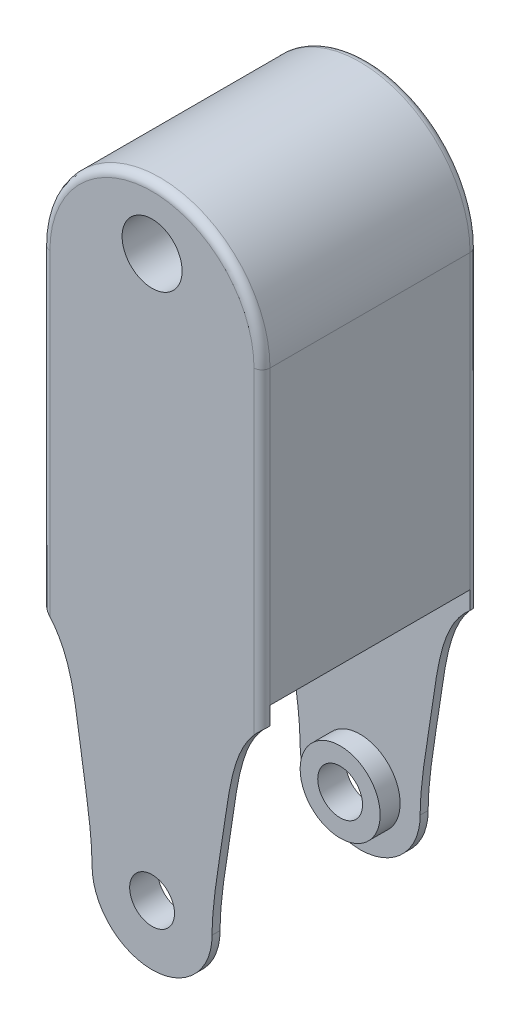
from build123d import *

# Parameters (mm, degrees)
CROQUIS1_R              = 5.6
CROQUIS1_R_2            = 7.5
SALIENTE_EXTRUIR1_DEPTH = 54
CROQUIS6_W              = 54
CROQUIS6_H              = 70
SALIENTE_EXTRUIR3_DEPTH = 74
CORTAR_EXTRUIR13_DEPTH  = 74
CORTAR_EXTRUIR14_DEPTH  = 74
CROQUIS9_W              = 3
CROQUIS9_H              = 11.2
CORTAR_EXTRUIR15_DEPTH  = 74
CROQUIS10_R             = 5.6
CORTAR_EXTRUIR16_DEPTH  = 74
CROQUIS11_R             = 10
CROQUIS11_R_2           = 5.6
SALIENTE_EXTRUIR4_DEPTH = 5
CROQUIS12_R             = 10
CROQUIS12_R_2           = 5.6
SALIENTE_EXTRUIR5_DEPTH = 5
CROQUIS13_W             = 50
CROQUIS13_H             = 73
CORTAR_EXTRUIR17_DEPTH  = 74
CROQUIS14_W             = 74
CROQUIS14_H             = 73
SALIENTE_EXTRUIR6_DEPTH = 54
CORTAR_EXTRUIR18_DEPTH  = 54
REDONDEO3_R             = 2
REDONDEO4_R             = 2


with BuildPart() as part:
    # Croquis1 → Saliente-Extruir1 (new body)
    with BuildSketch(Plane.XY):
        with BuildLine():
            Line((0, 143), (0, 70))
            add(Edge.make_bspline(
                [(22, 15), (22, 22.317960933), (17.777719643, 44.524463784), (15.903513438, 66.300635574), (0, 70)],
                knots=[0, 0, 0, 0, 0.399675276, 1, 1, 1, 1], degree=3))
            ThreePointArc((22, 15), (37, 0), (52, 15))
            add(Edge.make_bspline(
                [(52, 15), (52, 22.317960933), (56.222280357, 44.524463784), (58.096486562, 66.300635574), (74, 70)],
                knots=[0, 0, 0, 0, 0.399675276, 1, 1, 1, 1], degree=3))
            Line((74, 70), (74, 143))
            ThreePointArc((74, 143), (37, 180), (0, 143))
        make_face()
        with Locations((37, 15)):
            Circle(CROQUIS1_R, mode=Mode.SUBTRACT)
        with Locations((37, 155)):
            Circle(CROQUIS1_R_2, mode=Mode.SUBTRACT)
    extrude(amount=SALIENTE_EXTRUIR1_DEPTH)

    # Croquis6 → Saliente-Extruir3 (add)
    with BuildSketch(Plane.ZY):
        with Locations((27, 35)):
            Rectangle(CROQUIS6_W, CROQUIS6_H)
    extrude(amount=-SALIENTE_EXTRUIR3_DEPTH)

    # Croquis7 → Cortar-Extruir13 (cut)
    with BuildSketch(Plane(origin=(74, 0, 0), x_dir=(0, 0, -1), z_dir=(1, 0, 0))):
        Polygon((-52, 0), (-2, 0), (-2, 9.4), (-5, 9.4), (-5, 20.6), (-2, 20.6), (-2, 70), (-52, 70), (-52, 20.6), (-49, 20.6), (-49, 9.4), (-52, 9.4), align=None)
    extrude(amount=-CORTAR_EXTRUIR13_DEPTH, mode=Mode.SUBTRACT)

    # Croquis8 → Cortar-Extruir14 (cut)
    with BuildSketch(Plane(origin=(0, 0, 0), x_dir=(-1, 0, 0), z_dir=(0, 0, -1))):
        with BuildLine():
            add(Edge.make_bspline(
                [(-74, 70), (-58.096486562, 66.300635574), (-56.222280357, 44.524463784), (-52, 22.317960933), (-52, 15)],
                knots=[0, 0, 0, 0, 0.600324724, 1, 1, 1, 1], degree=3))
            Line((-74, 70), (-74, 0))
            Line((-74, 0), (-37, 0))
            ThreePointArc((-37, 0), (-47.606601718, 4.393398282), (-52, 15))
        make_face()
        with BuildLine():
            ThreePointArc((-22, 15), (-26.393398282, 4.393398282), (-37, 0))
            Line((-37, 0), (0, 0))
            Line((0, 0), (0, 70))
            add(Edge.make_bspline(
                [(-22, 15), (-22, 22.317960933), (-17.777719643, 44.524463784), (-15.903513438, 66.300635574), (0, 70)],
                knots=[0, 0, 0, 0, 0.399675276, 1, 1, 1, 1], degree=3))
        make_face()
    extrude(amount=-CORTAR_EXTRUIR14_DEPTH, mode=Mode.SUBTRACT)

    # Croquis9 → Cortar-Extruir15 (cut)
    with BuildSketch(Plane(origin=(74, 0, 0), x_dir=(0, 0, -1), z_dir=(1, 0, 0))):
        with Locations((-50.5, 15)):
            Rectangle(CROQUIS9_W, CROQUIS9_H)
        Polygon((-2, 20.6), (-5.198845147, 20.6), (-5, 9.4), (-2, 9.4), align=None)
    extrude(amount=-CORTAR_EXTRUIR15_DEPTH, mode=Mode.SUBTRACT)

    # Croquis10 → Cortar-Extruir16 (cut)
    with BuildSketch(Plane(origin=(0, 0, 0), x_dir=(-1, 0, 0), z_dir=(0, 0, -1))):
        with Locations((-37, 15)):
            Circle(CROQUIS10_R)
    extrude(amount=-CORTAR_EXTRUIR16_DEPTH, mode=Mode.SUBTRACT)

    # Croquis11 → Saliente-Extruir4 (add)
    with BuildSketch(Plane(origin=(0, 0, 52), x_dir=(-1, 0, 0), z_dir=(0, 0, -1))):
        with Locations(Location((-37, 15, 0), (0, 0, 270))):
            Circle(CROQUIS11_R)
        with Locations((-37, 15)):
            Circle(CROQUIS11_R_2, mode=Mode.SUBTRACT)
    extrude(amount=SALIENTE_EXTRUIR4_DEPTH)

    # Croquis12 → Saliente-Extruir5 (add)
    with BuildSketch(Plane.XY.offset(2)):
        with Locations(Location((37, 15, 0), (0, 0, 270))):
            Circle(CROQUIS12_R)
        with Locations(Location((37, 15, 0), (0, 0, 180))):
            Circle(CROQUIS12_R_2, mode=Mode.SUBTRACT)
    extrude(amount=SALIENTE_EXTRUIR5_DEPTH)

    # Croquis13 → Cortar-Extruir17 (cut)
    with BuildSketch(Plane.ZY):
        with Locations((27, 106.5)):
            Rectangle(CROQUIS13_W, CROQUIS13_H)
    extrude(amount=-CORTAR_EXTRUIR17_DEPTH, mode=Mode.SUBTRACT)

    # Croquis14 → Saliente-Extruir6 (add)
    with BuildSketch(Plane(origin=(0, 0, 0), x_dir=(-1, 0, 0), z_dir=(0, 0, -1))):
        with Locations((-37, 106.5)):
            Rectangle(CROQUIS14_W, CROQUIS14_H)
    extrude(amount=-SALIENTE_EXTRUIR6_DEPTH)

    # Croquis15 → Cortar-Extruir18 (cut)
    with BuildSketch(Plane.XY.offset(54)):
        with BuildLine():
            Line((9.470720421, 142.990900166), (9.470720421, 62.137684014))
            Line((9.470720421, 62.137684014), (-11.518865127, 62.137684014))
            Line((-11.518865127, 62.137684014), (-11.518865127, 188.692436646))
            Line((-11.518865127, 188.692436646), (98.86488905, 188.692436646))
            Line((98.86488905, 188.692436646), (98.86488905, 62.137684014))
            Line((98.86488905, 62.137684014), (64.470720421, 62.137684014))
            Line((64.470720421, 62.137684014), (64.470720421, 142.990900166))
            ThreePointArc((64.470720421, 142.990900166), (36.970720421, 170.490900166), (9.470720421, 142.990900166))
        make_face()
    extrude(amount=-CORTAR_EXTRUIR18_DEPTH, mode=Mode.SUBTRACT)

    # Redondeo3
    redondeo3_edges = [part.edges().sort_by_distance(p)[0] for p in [
        (9.470720421, 104.272545077, 54),
        (36.970720421, 170.490900166, 54),
        (64.470720421, 104.24810361, 54),
    ]]
    fillet(redondeo3_edges, radius=REDONDEO3_R)

    # Redondeo4
    redondeo4_edges = [part.edges().sort_by_distance(p)[0] for p in [
        (36.970720421, 170.490900166, 0),
        (9.470720421, 104.272545072, 0),
        (64.470720421, 104.248103603, 0),
    ]]
    fillet(redondeo4_edges, radius=REDONDEO4_R)


solid = part.part
